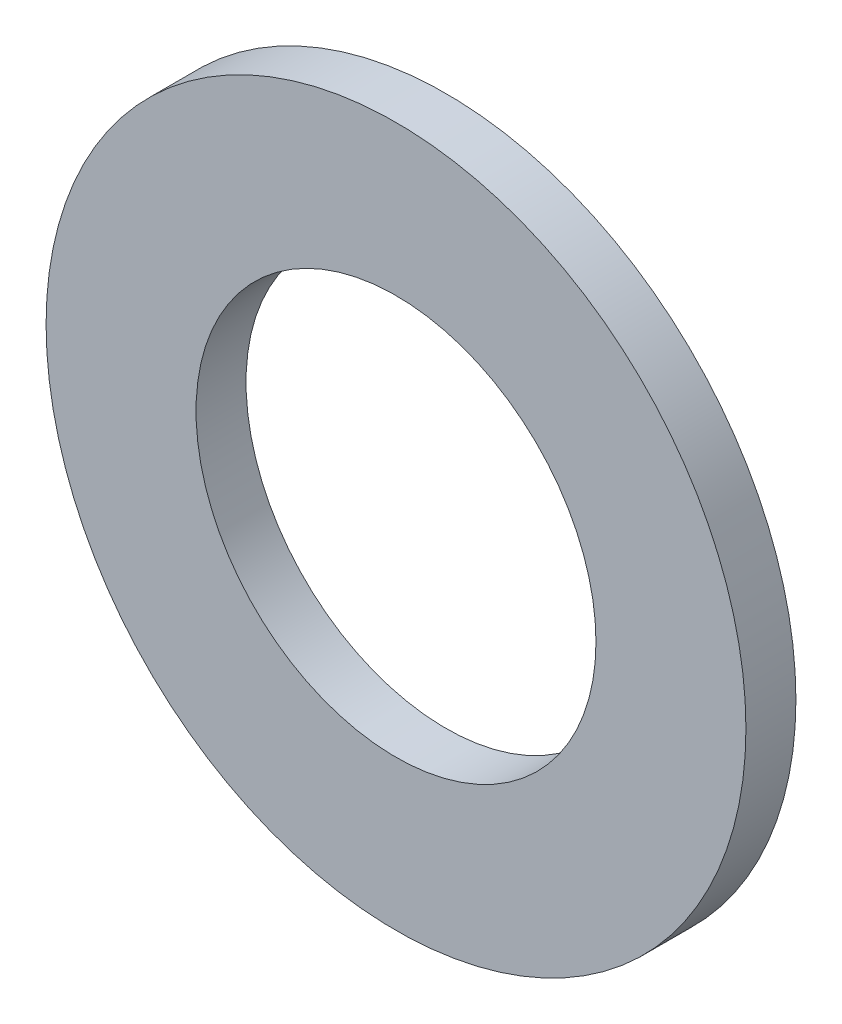
from build123d import *

# Parameters (mm, degrees)
SKETCH_1_R      = 7
SKETCH_1_R_2    = 4
EXTRUDE_1_DEPTH = 1


with BuildPart() as part:
    # Эскиз1 → Вытянуть-Тонкостенный1 (new body)
    with BuildSketch(Plane.XY):
        Circle(SKETCH_1_R)
        Circle(SKETCH_1_R_2, mode=Mode.SUBTRACT)
    extrude(amount=EXTRUDE_1_DEPTH)


solid = part.part
